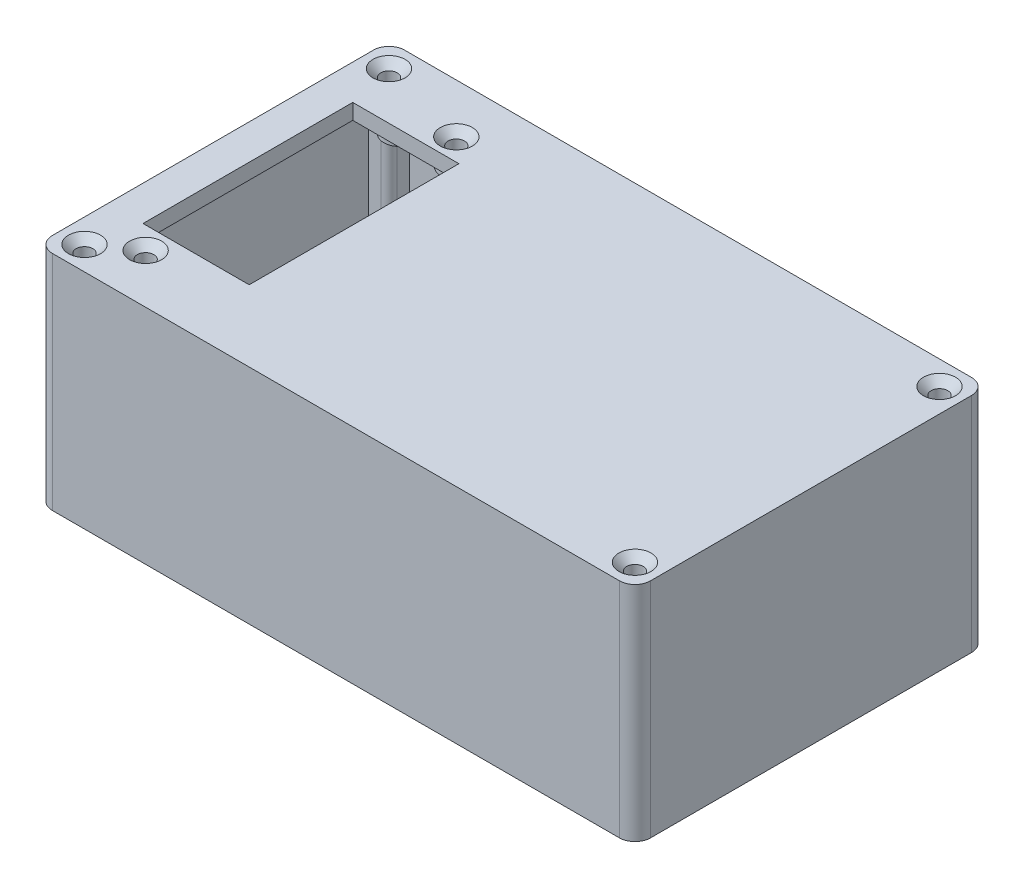
from build123d import *

# Parameters (mm, degrees)
SKETCH_3_W          = 109.5
SKETCH_3_H          = 62
EXTRUDE_2_DEPTH     = 40
SKETCH_5_R          = 1.6
EXTRUDE_2_2_DEPTH   = 40
SKETCH_7_R          = 1.6
EXTRUDE_3_DEPTH     = 3
CHAMFER_1_SIZE      = 1.5
SKETCH_9_R          = 3
SKETCH_9_R_2        = 0.75
EXTRUDE_4_DEPTH     = 3
SKETCH_10_R         = 1.6
SKETCH_10_W         = 20.5
SKETCH_10_H         = 40.5
CUT_EXTRUDE_1_DEPTH = 4
CHAMFER_2_SIZE      = 1.5
FILLET_2_R          = 1.5
FILLET_3_R          = 1.5
SKETCH_12_R         = 3
SKETCH_12_R_2       = 1.6
EXTRUDE_5_DEPTH     = 2


with BuildPart() as part:
    # Эскиз3 → Extrude 2 (new body)
    with BuildSketch(Plane(origin=(0, 0, 0), x_dir=(1, 0, 0), z_dir=(0, 1, 0))):
        with BuildLine():
            Line((-41.762564045, 34), (67.737435955, 34))
            ThreePointArc((67.737435955, 34), (69.858756299, 33.121320344), (70.737435955, 31))
            Line((70.737435955, 31), (70.737435955, -31))
            ThreePointArc((70.737435955, -31), (69.858756299, -33.121320344), (67.737435955, -34))
            Line((67.737435955, -34), (-41.762564045, -34))
            ThreePointArc((-41.762564045, -34), (-43.883884388, -33.121320344), (-44.762564045, -31))
            Line((-44.762564045, -31), (-44.762564045, 31))
            ThreePointArc((-44.762564045, 31), (-43.883884388, 33.121320344), (-41.762564045, 34))
        make_face()
        with Locations((12.987435955, 0)):
            Rectangle(SKETCH_3_W, SKETCH_3_H, mode=Mode.SUBTRACT)
    extrude(amount=EXTRUDE_2_DEPTH)

    # Эскиз5 → Extrude 2 2 (add)
    with BuildSketch(Plane.XZ):
        with BuildLine():
            Line((-43.498616626, 27), (-43.498616626, 32.026898844))
            Line((-43.498616626, 32.026898844), (-37.762564045, 32.026898844))
            Line((-37.762564045, 32.026898844), (-37.762564045, 28.5))
            ThreePointArc((-37.762564045, 28.5), (-38.201903873, 27.439339828), (-39.262564045, 27))
            Line((-39.262564045, 27), (-43.498616626, 27))
        make_face()
        with Locations((-40.162564045, 29.4)):
            Circle(SKETCH_5_R, mode=Mode.SUBTRACT)
        with BuildLine():
            Line((-43.498616626, -32.026898844), (-37.762564045, -32.026898844))
            Line((-37.762564045, -32.026898844), (-37.762564045, -28.5))
            ThreePointArc((-37.762564045, -28.5), (-38.201903873, -27.439339828), (-39.262564045, -27))
            Line((-39.262564045, -27), (-43.498616626, -27))
            Line((-43.498616626, -27), (-43.498616626, -32.026898844))
        make_face()
        with Locations((-40.162564045, -29.4)):
            Circle(SKETCH_5_R, mode=Mode.SUBTRACT)
        with BuildLine():
            Line((69.473488536, -27), (69.473488536, -32.026898844))
            Line((69.473488536, -32.026898844), (63.737435955, -32.026898844))
            Line((63.737435955, -32.026898844), (63.737435955, -28.5))
            ThreePointArc((63.737435955, -28.5), (64.176775783, -27.439339828), (65.237435955, -27))
            Line((65.237435955, -27), (69.473488536, -27))
        make_face()
        with Locations((66.137435955, -29.4)):
            Circle(SKETCH_5_R, mode=Mode.SUBTRACT)
        with BuildLine():
            Line((69.473488536, 32.026898844), (63.737435955, 32.026898844))
            Line((63.737435955, 32.026898844), (63.737435955, 28.5))
            ThreePointArc((63.737435955, 28.5), (64.176775783, 27.439339828), (65.237435955, 27))
            Line((65.237435955, 27), (69.473488536, 27))
            Line((69.473488536, 27), (69.473488536, 32.026898844))
        make_face()
        with Locations((66.137435955, 29.4)):
            Circle(SKETCH_5_R, mode=Mode.SUBTRACT)
    extrude(amount=-EXTRUDE_2_2_DEPTH)

    # Эскиз7 → Бобышка-Вытянуть3 (add)
    with BuildSketch(Plane(origin=(0, 40, 0), x_dir=(1, 0, 0), z_dir=(0, 1, 0))):
        with BuildLine():
            Line((70.737435955, -31), (70.737435955, 31))
            ThreePointArc((70.737435955, 31), (69.858756299, 33.121320344), (67.737435955, 34))
            Line((67.737435955, 34), (-41.762564045, 34))
            ThreePointArc((-41.762564045, 34), (-43.883884388, 33.121320344), (-44.762564045, 31))
            Line((-44.762564045, 31), (-44.762564045, -31))
            ThreePointArc((-44.762564045, -31), (-43.883884388, -33.121320344), (-41.762564045, -34))
            Line((-41.762564045, -34), (67.737435955, -34))
            ThreePointArc((67.737435955, -34), (69.858756299, -33.121320344), (70.737435955, -31))
        make_face()
        with Locations((66.137435955, 29.4)):
            Circle(SKETCH_7_R, mode=Mode.SUBTRACT)
        with Locations((66.137435955, -29.4)):
            Circle(SKETCH_7_R, mode=Mode.SUBTRACT)
        with Locations((-40.162564045, -29.4)):
            Circle(SKETCH_7_R, mode=Mode.SUBTRACT)
        with Locations((-40.162564045, 29.4)):
            Circle(SKETCH_7_R, mode=Mode.SUBTRACT)
    extrude(amount=EXTRUDE_3_DEPTH)

    # Фаска1
    chamfer_1_edges = [part.edges().sort_by_distance(p)[0] for p in [
        (64.537435955, 43, -29.4),
        (64.537435955, 43, 29.4),
        (-41.762564045, 43, 29.4),
        (-41.762564045, 43, -29.4),
    ]]
    chamfer(chamfer_1_edges, length=CHAMFER_1_SIZE)

    # Эскиз9 → Бобышка-Вытянуть4 (add)
    with BuildSketch(Plane.XZ.offset(-40)):
        with Locations((-6.762564044, 22.000000001)):
            Circle(SKETCH_9_R)
        with Locations((-6.762564044, 22.000000001)):
            Circle(SKETCH_9_R_2, mode=Mode.SUBTRACT)
        with Locations((57.237435954, 22.000000001)):
            Circle(SKETCH_9_R)
        with Locations((57.237435954, 22.000000001)):
            Circle(SKETCH_9_R_2, mode=Mode.SUBTRACT)
        with Locations((57.237435954, -21.999999999)):
            Circle(SKETCH_9_R)
        with Locations((57.237435954, -21.999999999)):
            Circle(SKETCH_9_R_2, mode=Mode.SUBTRACT)
        with Locations((-6.762564044, -21.999999999)):
            Circle(SKETCH_9_R)
        with Locations((-6.762564044, -21.999999999)):
            Circle(SKETCH_9_R_2, mode=Mode.SUBTRACT)
    extrude(amount=EXTRUDE_4_DEPTH)

    # Эскиз10 → Вырез-Вытянуть1 (cut, through all)
    with BuildSketch(Plane.XZ.offset(-40)):
        with Locations((-33.262564045, 24.5)):
            Circle(SKETCH_10_R)
        with Locations((-22.262564045, -24.5)):
            Circle(SKETCH_10_R)
        with Locations((-27.762564045, 0)):
            Rectangle(SKETCH_10_W, SKETCH_10_H)
    extrude(amount=-CUT_EXTRUDE_1_DEPTH, mode=Mode.SUBTRACT)

    # Фаска2
    chamfer_2_edges = [part.edges().sort_by_distance(p)[0] for p in [
        (-34.862564045, 43, 24.5),
        (-23.862564045, 43, -24.5),
    ]]
    chamfer(chamfer_2_edges, length=CHAMFER_2_SIZE)

    # Скругление2
    fillet_2_edges = [part.edges().sort_by_distance(p)[0] for p in [
        (12.987435955, 40, 31),
    ]]
    fillet(fillet_2_edges, radius=FILLET_2_R)

    # Скругление3
    fillet_3_edges = [part.edges().sort_by_distance(p)[0] for p in [
        (67.737435955, 40, 0),
        (-41.762564045, 40, 0),
        (12.987435955, 40, -31),
    ]]
    fillet(fillet_3_edges, radius=FILLET_3_R)

    # Эскиз12 → Бобышка-Вытянуть5 (add)
    with BuildSketch(Plane.XZ.offset(-40)):
        with Locations((-33.262564045, 24.5)):
            Circle(SKETCH_12_R)
        with Locations((-33.262564045, 24.5)):
            Circle(SKETCH_12_R_2, mode=Mode.SUBTRACT)
        with Locations((-22.262564045, -24.5)):
            Circle(SKETCH_12_R)
        with Locations((-22.262564045, -24.5)):
            Circle(SKETCH_12_R_2, mode=Mode.SUBTRACT)
        with Locations((-33.262564045, -24.5)):
            Circle(SKETCH_12_R)
        with Locations((-22.262564045, 24.5)):
            Circle(SKETCH_12_R)
    extrude(amount=EXTRUDE_5_DEPTH)


solid = part.part
